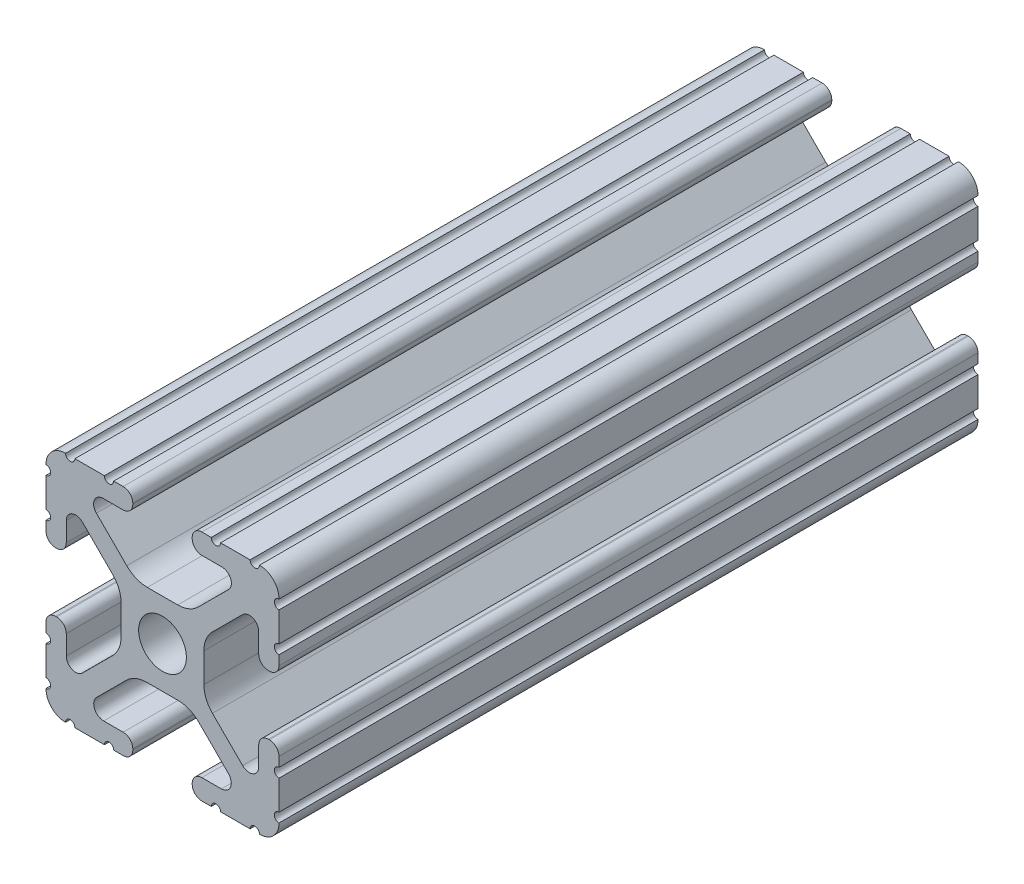
from build123d import *

# Parameters (mm, degrees)
SKETCH1_R      = 2.6035
EXTRUDE1_DEPTH = 76.2


with BuildPart() as part:
    # Sketch1 → Extrude1 (new body)
    with BuildSketch(Plane.XY):
        with BuildLine():
            Line((-7.207036008, 8.724370562), (-3.898272566, 5.423169045))
            ThreePointArc((-3.898272566, 5.423169045), (-2.869120213, 4.736787962), (-1.655778399, 4.4958))
            Line((-1.655778399, 4.4958), (1.655778399, 4.4958))
            ThreePointArc((1.655778399, 4.4958), (2.869120213, 4.736787962), (3.898272566, 5.423169045))
            Line((3.898272566, 5.423169045), (7.207036008, 8.724370562))
            ThreePointArc((7.207036008, 8.724370562), (7.432222385, 9.85140422), (6.476788598, 10.4902))
            Line((6.476788598, 10.4902), (4.287512407, 10.4902))
            ThreePointArc((4.287512407, 10.4902), (3.54574862, 10.79744862), (3.2385, 11.539212407))
            Line((3.2385, 11.539212407), (3.2385, 11.650987593))
            ThreePointArc((3.2385, 11.650987593), (3.54574862, 12.39275138), (4.287512407, 12.7))
            Line((4.287512407, 12.7), (5.317126718, 12.7))
            ThreePointArc((5.317126718, 12.7), (5.825126718, 12.192), (6.333126718, 12.7))
            Line((6.333126718, 12.7), (9.550443118, 12.7))
            ThreePointArc((9.550443118, 12.7), (10.058366869, 12.192000006), (10.566443095, 12.699847501))
            ThreePointArc((10.566443095, 12.699847501), (12.082537762, 12.08250727), (12.699846982, 10.566399977))
            ThreePointArc((12.699846982, 10.566399977), (12.192000006, 10.058323491), (12.7, 9.5504))
            Line((12.7, 9.5504), (12.7, 6.3330836))
            ThreePointArc((12.7, 6.3330836), (12.192, 5.8250836), (12.7, 5.3170836))
            Line((12.7, 5.3170836), (12.7, 4.287469289))
            ThreePointArc((12.7, 4.287469289), (12.39275138, 3.545705502), (11.650987593, 3.238456882))
            Line((11.650987593, 3.238456882), (11.539212407, 3.238456882))
            ThreePointArc((11.539212407, 3.238456882), (10.79744862, 3.545705502), (10.4902, 4.287469289))
            Line((10.4902, 4.287469289), (10.4902, 6.402089023))
            ThreePointArc((10.4902, 6.402089023), (9.856505071, 7.351067942), (8.737131347, 7.129408934))
            Line((8.737131347, 7.129408934), (5.441005833, 3.840816462))
            ThreePointArc((5.441005833, 3.840816462), (4.750877967, 2.809883091), (4.5085, 1.593185507))
            Line((4.5085, 1.593185507), (4.5085, -1.593185507))
            ThreePointArc((4.5085, -1.593185507), (4.750877967, -2.809883091), (5.441005833, -3.840816462))
            Line((5.441005833, -3.840816462), (8.737131347, -7.129408934))
            ThreePointArc((8.737131347, -7.129408934), (9.856505071, -7.351067942), (10.4902, -6.402089023))
            Line((10.4902, -6.402089023), (10.4902, -4.287469289))
            ThreePointArc((10.4902, -4.287469289), (10.79744862, -3.545705502), (11.539212407, -3.238456882))
            Line((11.539212407, -3.238456882), (11.650987593, -3.238456882))
            ThreePointArc((11.650987593, -3.238456882), (12.39275138, -3.545705502), (12.7, -4.287469289))
            Line((12.7, -4.287469289), (12.7, -5.3170836))
            ThreePointArc((12.7, -5.3170836), (12.192, -5.8250836), (12.7, -6.3330836))
            Line((12.7, -6.3330836), (12.7, -9.5504))
            ThreePointArc((12.7, -9.5504), (12.192000006, -10.058323491), (12.699846982, -10.566399977))
            ThreePointArc((12.699846982, -10.566399977), (12.082537762, -12.08250727), (10.566443095, -12.699847501))
            ThreePointArc((10.566443095, -12.699847501), (10.058366869, -12.192000006), (9.550443118, -12.7))
            Line((9.550443118, -12.7), (6.333126718, -12.7))
            ThreePointArc((6.333126718, -12.7), (5.825126718, -12.192), (5.317126718, -12.7))
            Line((5.317126718, -12.7), (4.287512407, -12.7))
            ThreePointArc((4.287512407, -12.7), (3.54574862, -12.39275138), (3.2385, -11.650987593))
            Line((3.2385, -11.650987593), (3.2385, -11.539212407))
            ThreePointArc((3.2385, -11.539212407), (3.54574862, -10.79744862), (4.287512407, -10.4902))
            Line((4.287512407, -10.4902), (6.416408329, -10.4902))
            ThreePointArc((6.416408329, -10.4902), (7.41473083, -9.822813117), (7.179650497, -8.645192506))
            Line((7.179650497, -8.645192506), (3.952270251, -5.423690499))
            ThreePointArc((3.952270251, -5.423690499), (2.922936451, -4.736929036), (1.709253557, -4.4958))
            Line((1.709253557, -4.4958), (-1.709253557, -4.4958))
            ThreePointArc((-1.709253557, -4.4958), (-2.922936451, -4.736929036), (-3.952270251, -5.423690499))
            Line((-3.952270251, -5.423690499), (-7.179650497, -8.645192506))
            ThreePointArc((-7.179650497, -8.645192506), (-7.41473083, -9.822813117), (-6.416408329, -10.4902))
            Line((-6.416408329, -10.4902), (-4.287512407, -10.4902))
            ThreePointArc((-4.287512407, -10.4902), (-3.54574862, -10.79744862), (-3.2385, -11.539212407))
            Line((-3.2385, -11.539212407), (-3.2385, -11.650987593))
            ThreePointArc((-3.2385, -11.650987593), (-3.54574862, -12.39275138), (-4.287512407, -12.7))
            Line((-4.287512407, -12.7), (-5.317126718, -12.7))
            ThreePointArc((-5.317126718, -12.7), (-5.825126718, -12.192), (-6.333126718, -12.7))
            Line((-6.333126718, -12.7), (-9.550443118, -12.7))
            ThreePointArc((-9.550443118, -12.7), (-10.058366869, -12.192000006), (-10.566443095, -12.699847501))
            ThreePointArc((-10.566443095, -12.699847501), (-12.082537762, -12.08250727), (-12.699846982, -10.566399977))
            ThreePointArc((-12.699846982, -10.566399977), (-12.192000006, -10.058323491), (-12.7, -9.5504))
            Line((-12.7, -9.5504), (-12.7, -6.3330836))
            ThreePointArc((-12.7, -6.3330836), (-12.192, -5.8250836), (-12.7, -5.3170836))
            Line((-12.7, -5.3170836), (-12.7, -4.287469289))
            ThreePointArc((-12.7, -4.287469289), (-12.39275138, -3.545705502), (-11.650987593, -3.238456882))
            Line((-11.650987593, -3.238456882), (-11.539212407, -3.238456882))
            ThreePointArc((-11.539212407, -3.238456882), (-10.79744862, -3.545705502), (-10.4902, -4.287469289))
            Line((-10.4902, -4.287469289), (-10.4902, -6.402089023))
            ThreePointArc((-10.4902, -6.402089023), (-9.856505071, -7.351067942), (-8.737131347, -7.129408934))
            Line((-8.737131347, -7.129408934), (-5.441005833, -3.840816462))
            ThreePointArc((-5.441005833, -3.840816462), (-4.750877967, -2.809883091), (-4.5085, -1.593185507))
            Line((-4.5085, -1.593185507), (-4.5085, 1.593185507))
            ThreePointArc((-4.5085, 1.593185507), (-4.750877967, 2.809883091), (-5.441005833, 3.840816462))
            Line((-5.441005833, 3.840816462), (-8.737131347, 7.129408934))
            ThreePointArc((-8.737131347, 7.129408934), (-9.856505071, 7.351067942), (-10.4902, 6.402089023))
            Line((-10.4902, 6.402089023), (-10.4902, 4.287469289))
            ThreePointArc((-10.4902, 4.287469289), (-10.79744862, 3.545705502), (-11.539212407, 3.238456882))
            Line((-11.539212407, 3.238456882), (-11.650987593, 3.238456882))
            ThreePointArc((-11.650987593, 3.238456882), (-12.39275138, 3.545705502), (-12.7, 4.287469289))
            Line((-12.7, 4.287469289), (-12.7, 5.3170836))
            ThreePointArc((-12.7, 5.3170836), (-12.192, 5.8250836), (-12.7, 6.3330836))
            Line((-12.7, 6.3330836), (-12.7, 9.5504))
            ThreePointArc((-12.7, 9.5504), (-12.192000006, 10.058323491), (-12.699846982, 10.566399977))
            ThreePointArc((-12.699846982, 10.566399977), (-12.082537762, 12.08250727), (-10.566443095, 12.699847501))
            ThreePointArc((-10.566443095, 12.699847501), (-10.058366869, 12.192000006), (-9.550443118, 12.7))
            Line((-9.550443118, 12.7), (-6.333126718, 12.7))
            ThreePointArc((-6.333126718, 12.7), (-5.825126718, 12.192), (-5.317126718, 12.7))
            Line((-5.317126718, 12.7), (-4.287512407, 12.7))
            ThreePointArc((-4.287512407, 12.7), (-3.54574862, 12.39275138), (-3.2385, 11.650987593))
            Line((-3.2385, 11.650987593), (-3.2385, 11.539212407))
            ThreePointArc((-3.2385, 11.539212407), (-3.54574862, 10.79744862), (-4.287512407, 10.4902))
            Line((-4.287512407, 10.4902), (-6.476788598, 10.4902))
            ThreePointArc((-6.476788598, 10.4902), (-7.432222385, 9.85140422), (-7.207036008, 8.724370562))
        make_face()
        Circle(SKETCH1_R, mode=Mode.SUBTRACT)
    extrude(amount=-EXTRUDE1_DEPTH)


solid = part.part
